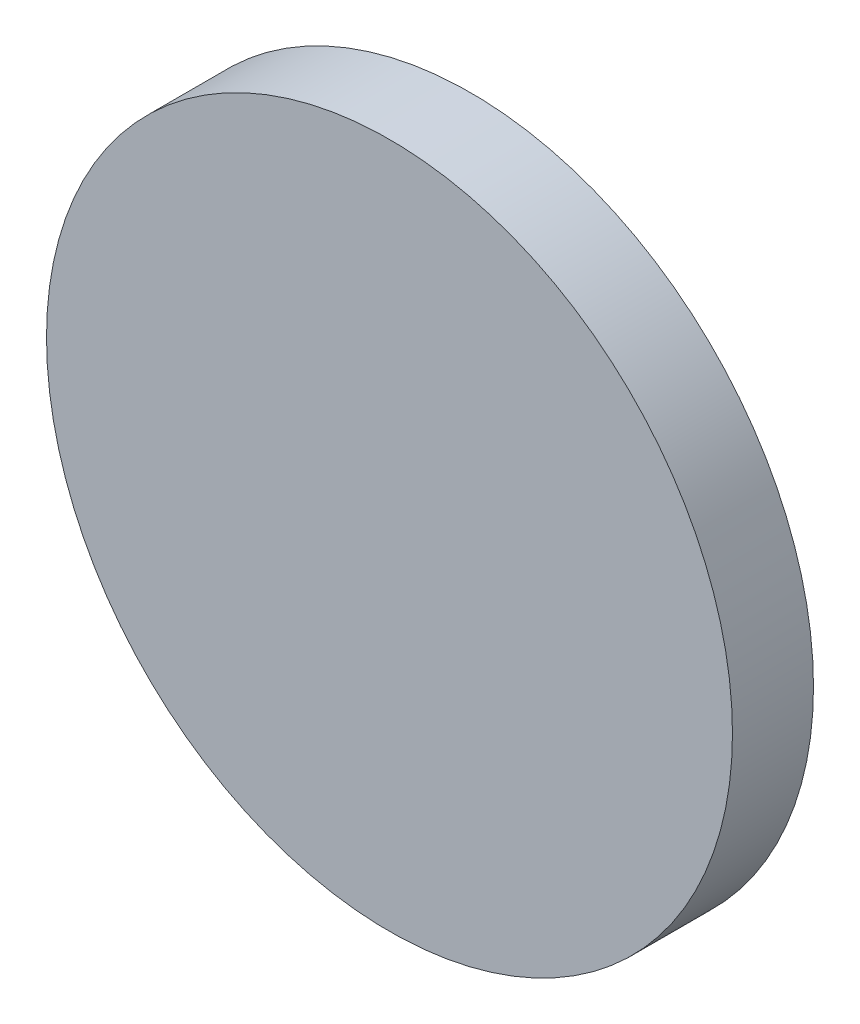
from build123d import *

# Parameters (mm, degrees)
SKETCH1_R      = 12.7
EXTRUDE1_DEPTH = 3


with BuildPart() as part:
    # Sketch1 → Extrude1 (new body)
    with BuildSketch(Plane.XY):
        Circle(SKETCH1_R)
    extrude(amount=EXTRUDE1_DEPTH)


solid = part.part
